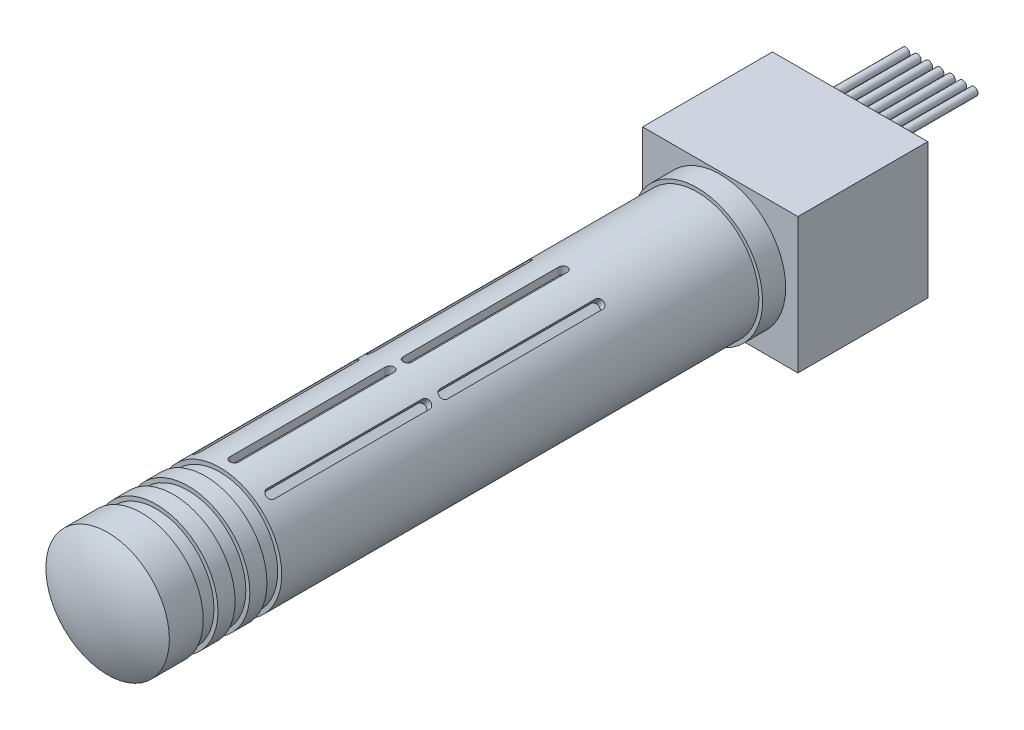
from build123d import *

# Parameters (mm, degrees)
SKETCH1_W           = 19.812
SKETCH1_H           = 17.272
BOSS_EXTRUDE1_DEPTH = 16.5608
SKETCH2_W           = 10.5156
SKETCH2_H           = 3.2766
BOSS_EXTRUDE2_DEPTH = 1.27
SKETCH3_R           = 8.3439
BOSS_EXTRUDE3_DEPTH = 2.9464
SKETCH4_R           = 7.874
BOSS_EXTRUDE4_DEPTH = 75.184
SKETCH6_R           = 0.508
WIRE_2_DEPTH        = 10.16
LPATTERN1_COUNT     = 7
LPATTERN1_PITCH     = 1.4478
CUT_EXTRUDE1_DEPTH  = 1.778
CIRPATTERN1_COUNT   = 10
SKETCH8_R           = 7.874
SKETCH8_R_2         = 7.366
CUT_EXTRUDE2_DEPTH  = 1.8796
LPATTERN2_COUNT     = 3
LPATTERN2_PITCH     = 4.064


with BuildPart() as part:
    # Sketch1 → Boss-Extrude1 (new body)
    with BuildSketch(Plane.XY):
        Rectangle(SKETCH1_W, SKETCH1_H)
    extrude(amount=BOSS_EXTRUDE1_DEPTH)

    # Sketch2 → Boss-Extrude2 (add)
    with BuildSketch(Plane(origin=(0, 0, 0), x_dir=(-1, 0, 0), z_dir=(0, 0, -1))):
        with Locations((0, 5.7277)):
            Rectangle(SKETCH2_W, SKETCH2_H)
    extrude(amount=BOSS_EXTRUDE2_DEPTH)

    # Sketch3 → Boss-Extrude3 (add)
    with BuildSketch(Plane.XY.offset(16.5608)):
        Circle(SKETCH3_R)
    extrude(amount=BOSS_EXTRUDE3_DEPTH)

    # Sketch4 → Boss-Extrude4 (add)
    with BuildSketch(Plane.XY.offset(19.5072)):
        Circle(SKETCH4_R)
    extrude(amount=BOSS_EXTRUDE4_DEPTH)

    # Sketch5 → Revolve1 (revolve)
    with BuildSketch(Plane(origin=(0, 0, 0), x_dir=(1, 0, 0), z_dir=(0, 1, 0))):
        with BuildLine():
            Line((0, -96.8502), (0, -94.6912))
            Line((0, -94.6912), (7.874, -94.6912))
            ThreePointArc((7.874, -94.6912), (4.082314203, -96.300669445), (0, -96.8502))
        make_face()
    revolve(axis=Axis((0, 0, 96.8502), (0, 0, -1)))

    # Sketch6 → Wire 2 (add)
    with BuildSketch(Plane(origin=(0, 0, -1.27), x_dir=(-1, 0, 0), z_dir=(0, 0, -1))):
        with Locations((-4.3688, 5.7277)):
            Circle(SKETCH6_R)
    wire_2 = extrude(amount=WIRE_2_DEPTH)

    # LPattern1: Wire 2 ×7
    with Locations(*[(-i * LPATTERN1_PITCH, 0, 0) for i in range(1, LPATTERN1_COUNT)]):
        add(wire_2)

    # Sketch7 → Cut-Extrude1 (cut)
    with BuildSketch(Plane(origin=(0, 8.636, 0), x_dir=(1, 0, 0), z_dir=(0, 1, 0))):
        with BuildLine():
            Line((0.5715, -36.6268), (0.5715, -56.4388))
            ThreePointArc((0.5715, -56.4388), (0, -57.0103), (-0.5715, -56.4388))
            Line((-0.5715, -56.4388), (-0.5715, -36.6268))
            ThreePointArc((-0.5715, -36.6268), (0, -36.0553), (0.5715, -36.6268))
        make_face()
        with BuildLine():
            Line((0.5715, -58.7248), (0.5715, -78.5368))
            ThreePointArc((0.5715, -78.5368), (0, -79.1083), (-0.5715, -78.5368))
            Line((-0.5715, -78.5368), (-0.5715, -58.7248))
            ThreePointArc((-0.5715, -58.7248), (0, -58.1533), (0.5715, -58.7248))
        make_face()
    cut_extrude1 = extrude(amount=-CUT_EXTRUDE1_DEPTH, mode=Mode.SUBTRACT)

    # CirPattern1: Cut-Extrude1 ×10 about axis, 4 skipped
    cirpattern1_axis = Axis((0, 0, 0), (0, 0, -1))
    add([cut_extrude1.rotate(cirpattern1_axis, i * 360 / CIRPATTERN1_COUNT) for i in range(1, CIRPATTERN1_COUNT) if i not in (2, 3, 7, 8)], mode=Mode.SUBTRACT)

    # Sketch8 → Cut-Extrude2 (cut)
    with BuildSketch(Plane.XY.offset(82.2452)):
        Circle(SKETCH8_R)
        Circle(SKETCH8_R_2, mode=Mode.SUBTRACT)
    cut_extrude2 = extrude(amount=-CUT_EXTRUDE2_DEPTH, mode=Mode.SUBTRACT)

    # LPattern2: Cut-Extrude2 ×3
    with Locations(*[(0, 0, i * LPATTERN2_PITCH) for i in range(1, LPATTERN2_COUNT)]):
        add(cut_extrude2, mode=Mode.SUBTRACT)


solid = part.part
